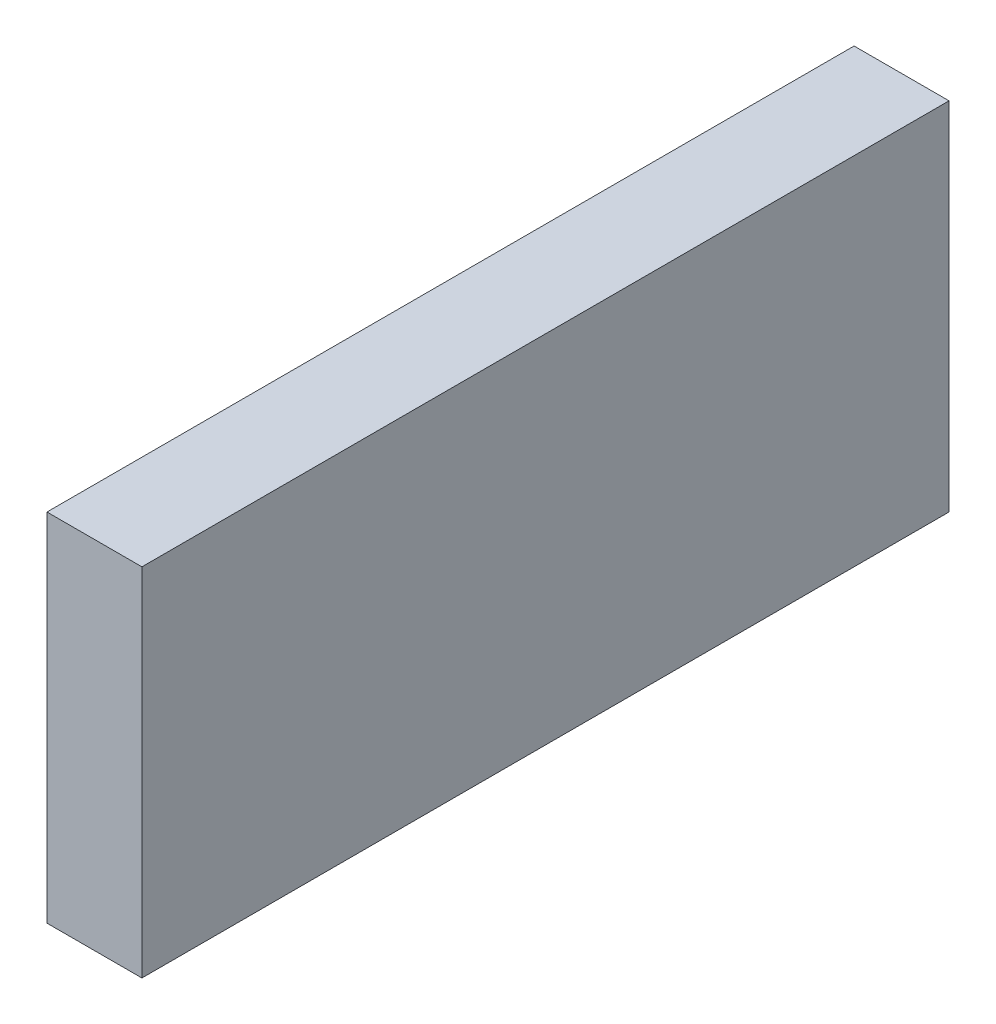
from build123d import *

# Parameters (mm, degrees)
SKETCH1_W           = 40
SKETCH1_H           = 340
BOSS_EXTRUDE1_DEPTH = 150


with BuildPart() as part:
    # Sketch1 → Boss-Extrude1 (new body)
    with BuildSketch(Plane(origin=(0, 0, 0), x_dir=(1, 0, 0), z_dir=(0, 1, 0))):
        Rectangle(SKETCH1_W, SKETCH1_H)
    extrude(amount=BOSS_EXTRUDE1_DEPTH)


solid = part.part
